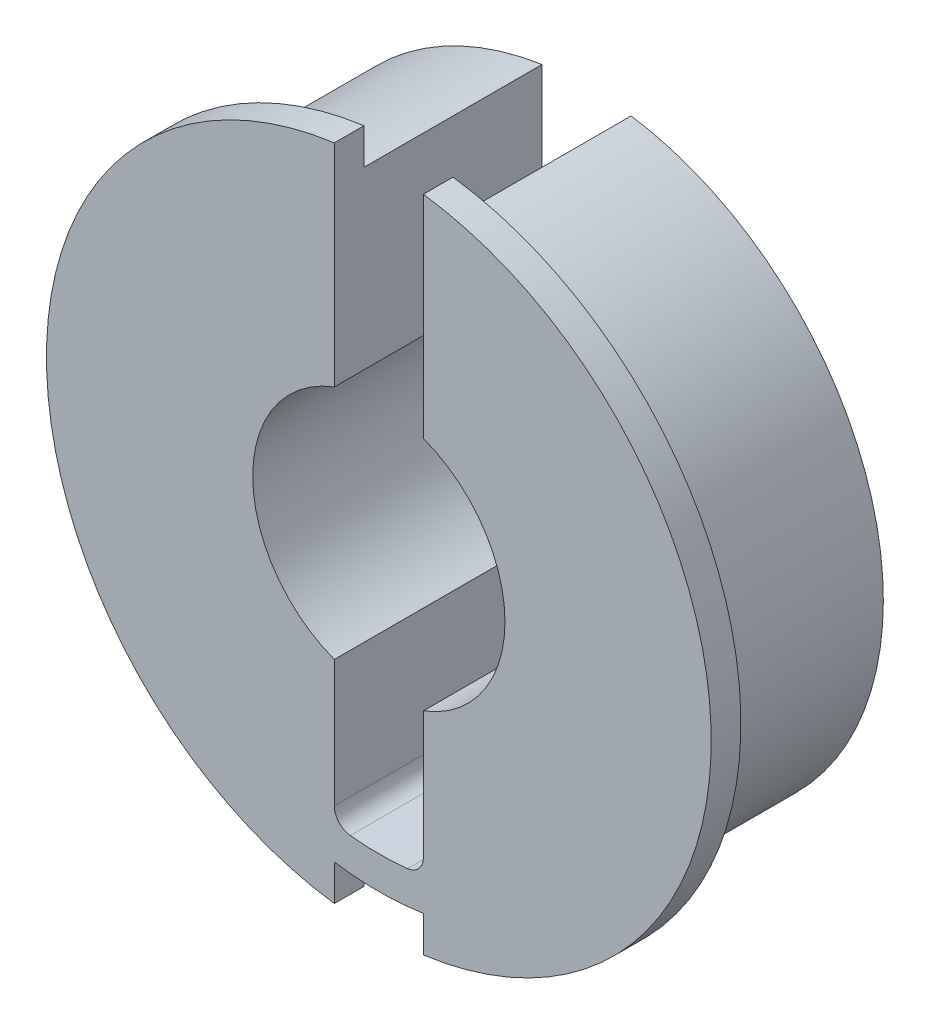
from build123d import *

# Parameters (mm, degrees)
SKETCH1_R           = 12.7
SKETCH1_R_2         = 5.3975
BOSS_EXTRUDE1_DEPTH = 7.62
SKETCH2_R           = 14.224
SKETCH2_R_2         = 5.3975
BOSS_EXTRUDE2_DEPTH = 1.27
CUT_EXTRUDE1_DEPTH  = 9.89
CUT_EXTRUDE2_DEPTH  = 2.27
FILLET1_R           = 0.762


with BuildPart() as part:
    # Sketch1 → Boss-Extrude1 (new body)
    with BuildSketch(Plane.XY):
        Circle(SKETCH1_R)
        Circle(SKETCH1_R_2, mode=Mode.SUBTRACT)
    extrude(amount=BOSS_EXTRUDE1_DEPTH)

    # Sketch2 → Boss-Extrude2 (add)
    with BuildSketch(Plane.XY.offset(7.62)):
        Circle(SKETCH2_R)
        Circle(SKETCH2_R_2, mode=Mode.SUBTRACT)
    extrude(amount=BOSS_EXTRUDE2_DEPTH)

    # Sketch3 → Cut-Extrude1 (cut, through all)
    with BuildSketch(Plane(origin=(0, 0, 0), x_dir=(-1, 0, 0), z_dir=(0, 0, -1))):
        with BuildLine():
            Line((-1.905, 14.224), (1.905, 14.224))
            Line((1.905, 14.224), (1.905, -11.141309797))
            ThreePointArc((1.905, -11.141309797), (0, -11.303), (-1.905, -11.141309797))
            Line((-1.905, -11.141309797), (-1.905, 14.224))
        make_face()
    extrude(amount=-CUT_EXTRUDE1_DEPTH, mode=Mode.SUBTRACT)

    # Sketch4 → Cut-Extrude2 (cut, through all)
    with BuildSketch(Plane(origin=(0, 0, 7.62), x_dir=(-1, 0, 0), z_dir=(0, 0, -1))):
        with BuildLine():
            Line((-1.905, -14.224), (-1.905, -12.556312158))
            ThreePointArc((-1.905, -12.556312158), (0, -12.7), (1.905, -12.556312158))
            Line((1.905, -12.556312158), (1.905, -14.224))
            Line((1.905, -14.224), (-1.905, -14.224))
        make_face()
    extrude(amount=-CUT_EXTRUDE2_DEPTH, mode=Mode.SUBTRACT)

    # Fillet1
    fillet1_edges = [part.edges().sort_by_distance(p)[0] for p in [
        (1.905, -11.141309797, 4.445),
        (-1.905, -11.141309797, 4.445),
    ]]
    fillet(fillet1_edges, radius=FILLET1_R)


solid = part.part
